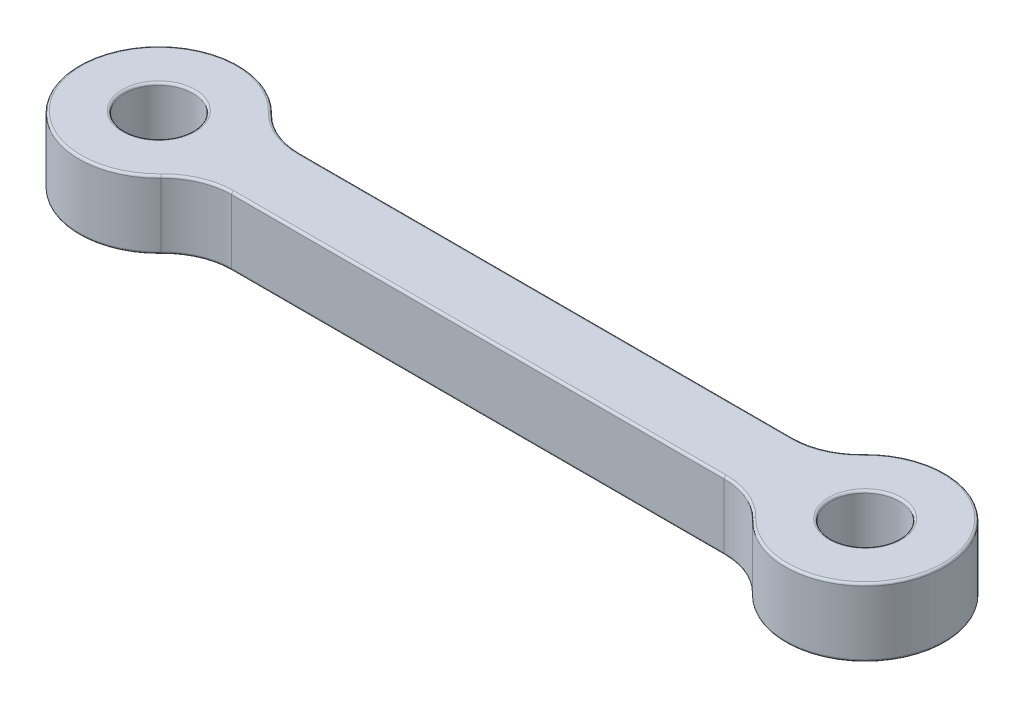
from build123d import *

# Parameters (mm, degrees)
SKETCH1_R           = 1.5
BOSS_EXTRUDE1_DEPTH = 3
FILLET1_R           = 0.1
SCALE1_SCALE        = 1.8


with BuildPart() as part:
    # Sketch1 → Boss-Extrude1 (new body)
    with BuildSketch(Plane(origin=(0, 0, 0), x_dir=(1, 0, 0), z_dir=(0, 1, 0))):
        with BuildLine():
            Line((4.69041576, 1.5), (26.30958424, 1.5))
            ThreePointArc((26.30958424, 1.5), (27.486281051, 1.740401367), (28.474391514, 2.423076923))
            ThreePointArc((28.474391514, 2.423076923), (34.5, 0), (28.474391514, -2.423076923))
            ThreePointArc((28.474391514, -2.423076923), (27.486281051, -1.740401367), (26.30958424, -1.5))
            Line((26.30958424, -1.5), (4.69041576, -1.5))
            ThreePointArc((4.69041576, -1.5), (3.513718949, -1.740401367), (2.525608486, -2.423076923))
            ThreePointArc((2.525608486, -2.423076923), (-3.5, 0), (2.525608486, 2.423076923))
            ThreePointArc((2.525608486, 2.423076923), (3.513718949, 1.740401367), (4.69041576, 1.5))
        make_face()
        Circle(SKETCH1_R, mode=Mode.SUBTRACT)
        with Locations((31, 0)):
            Circle(SKETCH1_R, mode=Mode.SUBTRACT)
    extrude(amount=BOSS_EXTRUDE1_DEPTH)

    # Fillet1
    fillet1_edges = [part.edges().sort_by_distance(p)[0] for p in [
        (27.486281051, 0, -1.740401367),
        (34.5, 0, 0),
        (29.5, 3, 0),
        (27.486281051, 0, 1.740401367),
        (15.5, 0, 1.5),
        (3.513718949, 0, 1.740401367),
        (-3.5, 0, 0),
        (3.513718949, 0, -1.740401367),
        (15.5, 0, -1.5),
        (29.5, 0, 0),
        (-1.5, 0, 0),
        (15.5, 3, -1.5),
        (3.513718949, 3, -1.740401367),
        (-3.5, 3, 0),
        (3.513718949, 3, 1.740401367),
        (15.5, 3, 1.5),
        (27.486281051, 3, 1.740401367),
        (34.5, 3, 0),
        (27.486281051, 3, -1.740401367),
        (-1.5, 3, 0),
    ]]
    fillet(fillet1_edges, radius=FILLET1_R)


with BuildPart() as part_1:
    # Scale1: scaled about (15.5, 1.5, 0)
    add(part.part.scale(SCALE1_SCALE).moved(Location((-12.4, -1.2, 0))))


solid = part_1.part
